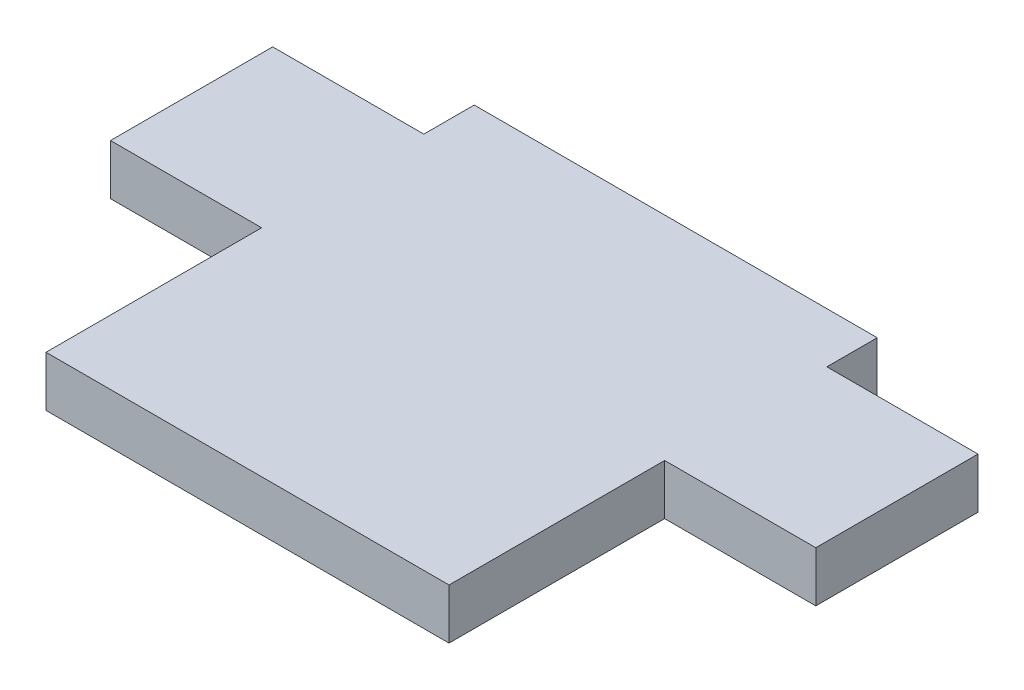
from build123d import *

# Parameters (mm, degrees)
BOSS_EXTRUDE1_DEPTH = 3.175


with BuildPart() as part:
    # Sketch1 → Boss-Extrude1 (new body)
    with BuildSketch(Plane(origin=(0, 0, 0), x_dir=(1, 0, 0), z_dir=(0, 1, 0))):
        Polygon((0, 13.3985), (-25.4, 13.3985), (-25.4, 10.2235), (-34.925, 10.2235), (-34.925, 0), (-25.4, 0), (-25.4, -13.589), (0, -13.589), (0, 0), (9.525, 0), (9.525, 10.2235), (0, 10.2235), align=None)
    extrude(amount=BOSS_EXTRUDE1_DEPTH)


solid = part.part
